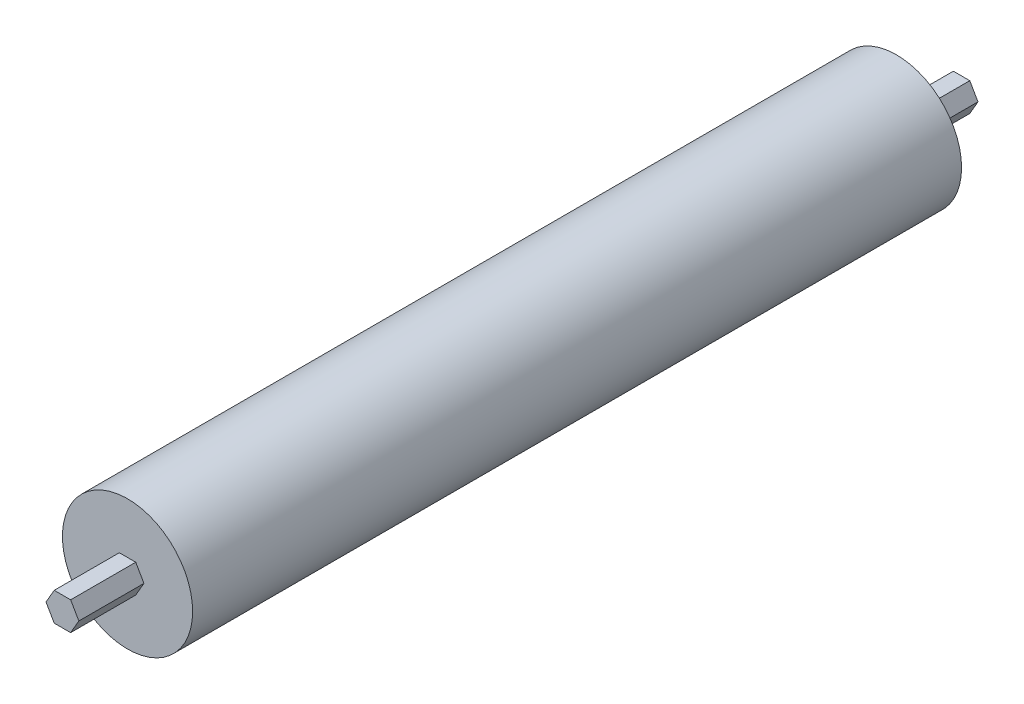
from build123d import *

# Parameters (mm, degrees)
SKETCH1_R           = 25.4
BOSS_EXTRUDE1_DEPTH = 300
BOSS_EXTRUDE2_DEPTH = 25.4
BOSS_EXTRUDE3_DEPTH = 25.4


with BuildPart() as part:
    # Sketch1 → Boss-Extrude1 (new body)
    with BuildSketch(Plane.XY):
        Circle(SKETCH1_R)
    extrude(amount=BOSS_EXTRUDE1_DEPTH)

    # Sketch2 → Boss-Extrude2 (add)
    with BuildSketch(Plane.XY.offset(300)):
        Polygon((6.408587988, 0), (3.204293994, 5.55), (-3.204293994, 5.55), (-6.408587988, 0), (-3.204293994, -5.55), (3.204293994, -5.55), align=None)
    extrude(amount=BOSS_EXTRUDE2_DEPTH)

    # Sketch3 → Boss-Extrude3 (add)
    with BuildSketch(Plane(origin=(0, 0, 0), x_dir=(-1, 0, 0), z_dir=(0, 0, -1))):
        Polygon((6.408587988, 0), (3.204293994, 5.55), (-3.204293994, 5.55), (-6.408587988, 0), (-3.204293994, -5.55), (3.204293994, -5.55), align=None)
    extrude(amount=BOSS_EXTRUDE3_DEPTH)


solid = part.part
